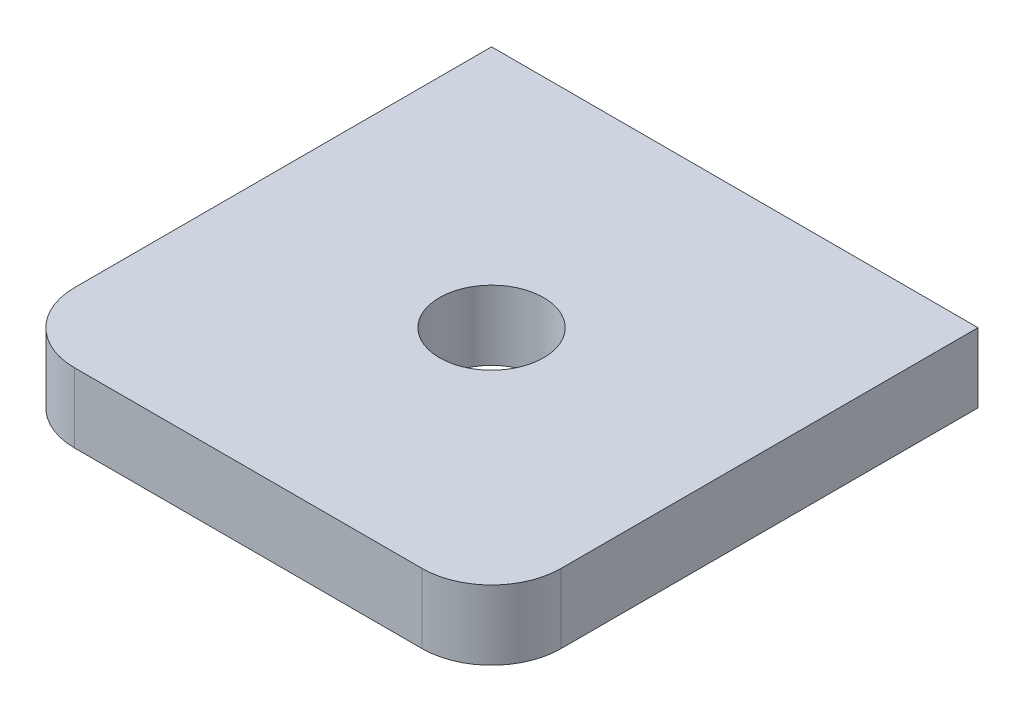
from build123d import *

# Parameters (mm, degrees)
CROQUIS1_R              = 7.5
SALIENTE_EXTRUIR1_DEPTH = 10


with BuildPart() as part:
    # Croquis1 → Saliente-Extruir1 (new body)
    with BuildSketch(Plane(origin=(0, 0, 0), x_dir=(1, 0, 0), z_dir=(0, 1, 0))):
        with BuildLine():
            Line((-35, 35), (35, 35))
            Line((35, 35), (35, -25))
            ThreePointArc((35, -25), (32.071067812, -32.071067812), (25, -35))
            Line((25, -35), (-25, -35))
            ThreePointArc((-25, -35), (-32.071067812, -32.071067812), (-35, -25))
            Line((-35, -25), (-35, 35))
        make_face()
        Circle(CROQUIS1_R, mode=Mode.SUBTRACT)
    extrude(amount=SALIENTE_EXTRUIR1_DEPTH)


solid = part.part
